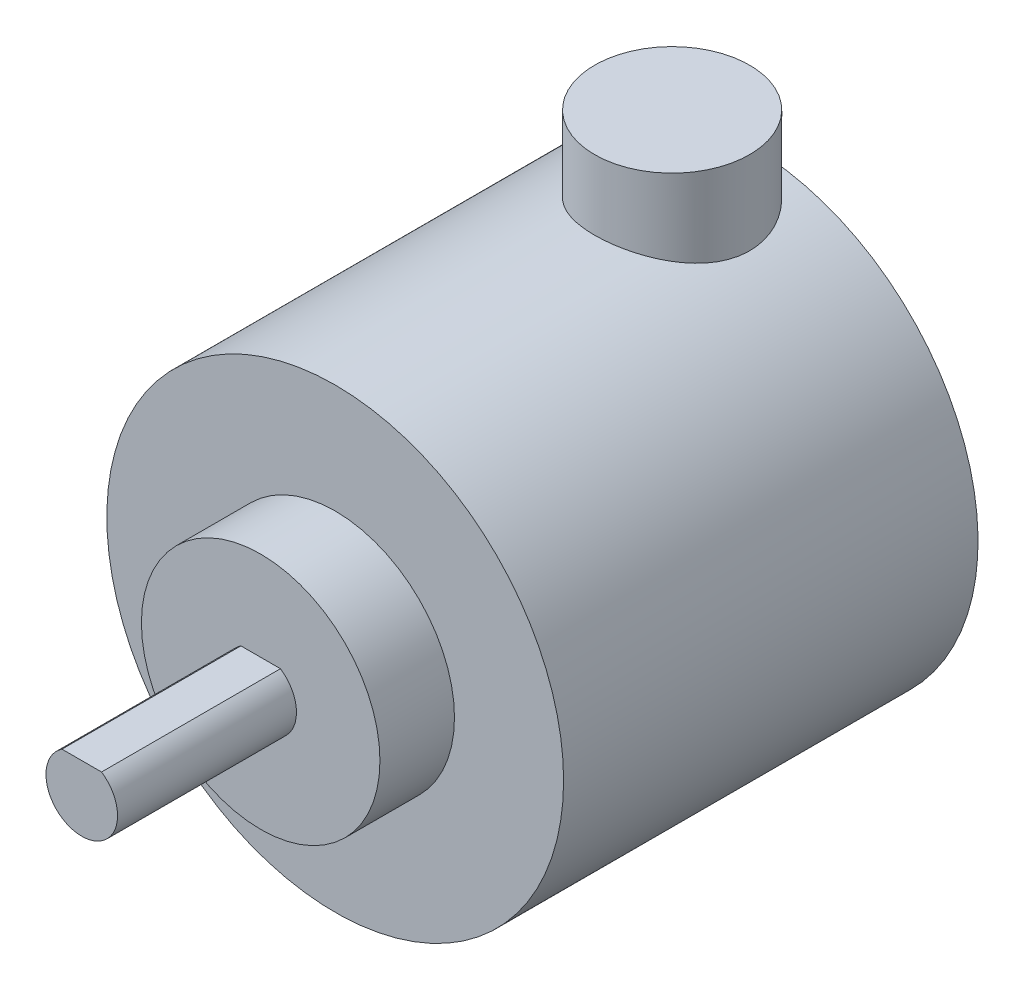
from build123d import *

# Parameters (mm, degrees)
SKETCH1_R           = 19.15
BOSS_EXTRUDE1_DEPTH = 34.75
SKETCH2_R           = 10
BOSS_EXTRUDE2_DEPTH = 6.25
SKETCH3_R           = 3
BOSS_EXTRUDE3_DEPTH = 15
CUT_EXTRUDE1_DEPTH  = 15
SKETCH5_R           = 6.5
BOSS_EXTRUDE4_DEPTH = 25


with BuildPart() as part:
    # Sketch1 → Boss-Extrude1 (new body)
    with BuildSketch(Plane.XY):
        Circle(SKETCH1_R)
    extrude(amount=BOSS_EXTRUDE1_DEPTH)

    # Sketch2 → Boss-Extrude2 (add)
    with BuildSketch(Plane.XY.offset(34.75)):
        Circle(SKETCH2_R)
    extrude(amount=BOSS_EXTRUDE2_DEPTH)

    # Sketch3 → Boss-Extrude3 (add)
    with BuildSketch(Plane.XY.offset(41)):
        Circle(SKETCH3_R)
    extrude(amount=BOSS_EXTRUDE3_DEPTH)

    # Sketch4 → Cut-Extrude1 (cut)
    with BuildSketch(Plane.XY.offset(56)):
        with BuildLine():
            Line((-1.658312395, 2.5), (1.658312395, 2.5))
            ThreePointArc((1.658312395, 2.5), (0, 3), (-1.658312395, 2.5))
        make_face()
    extrude(amount=-CUT_EXTRUDE1_DEPTH, mode=Mode.SUBTRACT)

    # Sketch5 → Boss-Extrude4 (add)
    with BuildSketch(Plane(origin=(0, 0, 0), x_dir=(1, 0, 0), z_dir=(0, 1, 0))):
        with Locations((0, -6.5)):
            Circle(SKETCH5_R)
    extrude(amount=BOSS_EXTRUDE4_DEPTH)


solid = part.part
